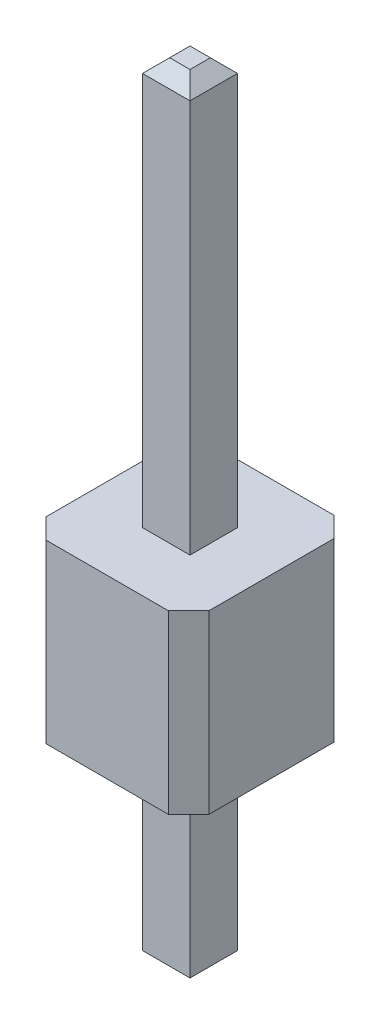
from build123d import *

# Parameters (mm, degrees)
EXTRUDE_1_DEPTH = 2.6
SKETCH_2_W      = 0.7
SKETCH_2_H      = 0.7
EXTRUDE_2_DEPTH = 6
SKETCH_3_W      = 0.7
SKETCH_3_H      = 0.7
EXTRUDE_3_DEPTH = 3
CHAMFER_1_SIZE  = 0.2


with BuildPart() as part:
    # Эскиз1 → Бобышка-Вытянуть1 (new body)
    with BuildSketch(Plane(origin=(0, 0, 0), x_dir=(1, 0, 0), z_dir=(0, 1, 0))):
        Polygon((-2.641860465, 1.681395349), (-2.341860465, 1.981395349), (-0.541860465, 1.981395349), (-0.241860465, 1.681395349), (-0.241860465, -0.158604651), (-0.541860465, -0.458604651), (-2.341860465, -0.458604651), (-2.641860465, -0.158604651), align=None)
    extrude(amount=EXTRUDE_1_DEPTH)

    # Эскиз2 → Бобышка-Вытянуть2 (add)
    with BuildSketch(Plane(origin=(0, 2.6, 0), x_dir=(1, 0, 0), z_dir=(0, 1, 0))):
        with Locations((-1.441860465, 0.761395349)):
            Rectangle(SKETCH_2_W, SKETCH_2_H)
    extrude(amount=EXTRUDE_2_DEPTH)

    # Эскиз3 → Бобышка-Вытянуть3 (add)
    with BuildSketch(Plane.XZ):
        with Locations((-1.441860465, -0.761395349)):
            Rectangle(SKETCH_3_W, SKETCH_3_H)
    extrude(amount=EXTRUDE_3_DEPTH)

    # Фаска1
    chamfer_1_edges = [part.edges().sort_by_distance(p)[0] for p in [
        (-1.791860465, -3, -0.761395349),
        (-1.441860465, -3, -0.411395349),
        (-1.091860465, -3, -0.761395349),
        (-1.441860465, -3, -1.111395349),
        (-1.441860465, 8.6, -0.411395349),
        (-1.091860465, 8.6, -0.761395349),
        (-1.441860465, 8.6, -1.111395349),
        (-1.791860465, 8.6, -0.761395349),
    ]]
    chamfer(chamfer_1_edges, length=CHAMFER_1_SIZE)


solid = part.part
